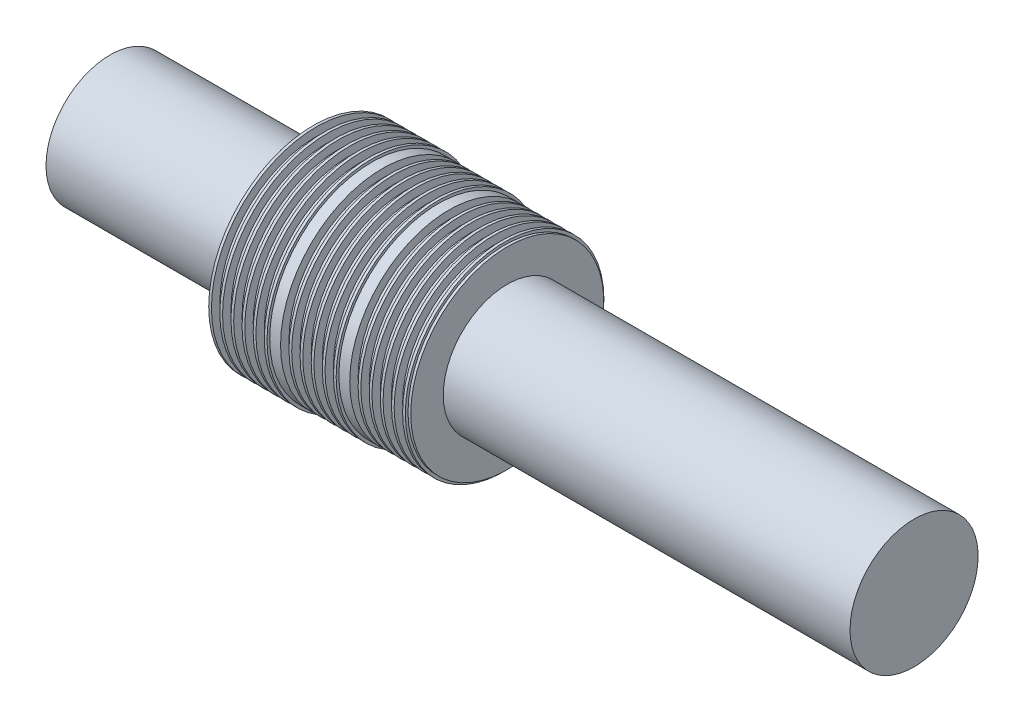
from build123d import *


with BuildPart() as part:
    # Sketch1 → Revolve1 (revolve)
    with BuildSketch(Plane.XY):
        Polygon((19.05, 9.809988), (19.304, 9.809988), (19.304, 9.022588), (20.0914, 9.022588), (20.0914, 9.809988), (20.3454, 9.809988), (20.3454, 9.022588), (21.1328, 9.022588), (21.1328, 9.809988), (21.3868, 9.809988), (21.3868, 9.022588), (22.1742, 9.022588), (22.1742, 9.809988), (22.4282, 9.809988), (22.4282, 9.022588), (23.2156, 9.022588), (23.2156, 9.809988), (23.4696, 9.809988), (23.4696, 9.022588), (24.257, 9.022588), (24.257, 9.809988), (24.511, 9.809988), (24.511, 9.555988), (25.527, 9.555988), (25.527, 8.768588), (26.3144, 8.768588), (26.3144, 9.555988), (26.5684, 9.555988), (26.5684, 8.768588), (27.3558, 8.768588), (27.3558, 9.555988), (27.6098, 9.555988), (27.6098, 8.768588), (28.3972, 8.768588), (28.3972, 9.555988), (28.6512, 9.555988), (28.6512, 8.768588), (29.4386, 8.768588), (29.4386, 9.555988), (29.6926, 9.555988), (29.6926, 8.768588), (30.48, 8.768588), (30.48, 9.555988), (30.734, 9.555988), (30.734, 9.301988), (31.75, 9.301988), (31.75, 8.514588), (32.5374, 8.514588), (32.5374, 9.301988), (32.7914, 9.301988), (32.7914, 8.514588), (33.5788, 8.514588), (33.5788, 9.301988), (33.8328, 9.301988), (33.8328, 8.514588), (34.6202, 8.514588), (34.6202, 9.301988), (34.8742, 9.301988), (34.8742, 8.514588), (35.6616, 8.514588), (35.6616, 9.301988), (35.9156, 9.301988), (35.9156, 8.514588), (36.703, 8.514588), (36.703, 9.301988), (36.957, 9.301988), (36.957, 9.047988), (37.211, 9.047988), (37.211, 5.999988), (75.311, 5.999988), (75.311, 0), (61.976, 0), (0, 0), (0, 5.999988), (19.05, 5.999988), align=None)
    revolve(axis=Axis((0, 0, 0), (1, 0, 0)))


solid = part.part
